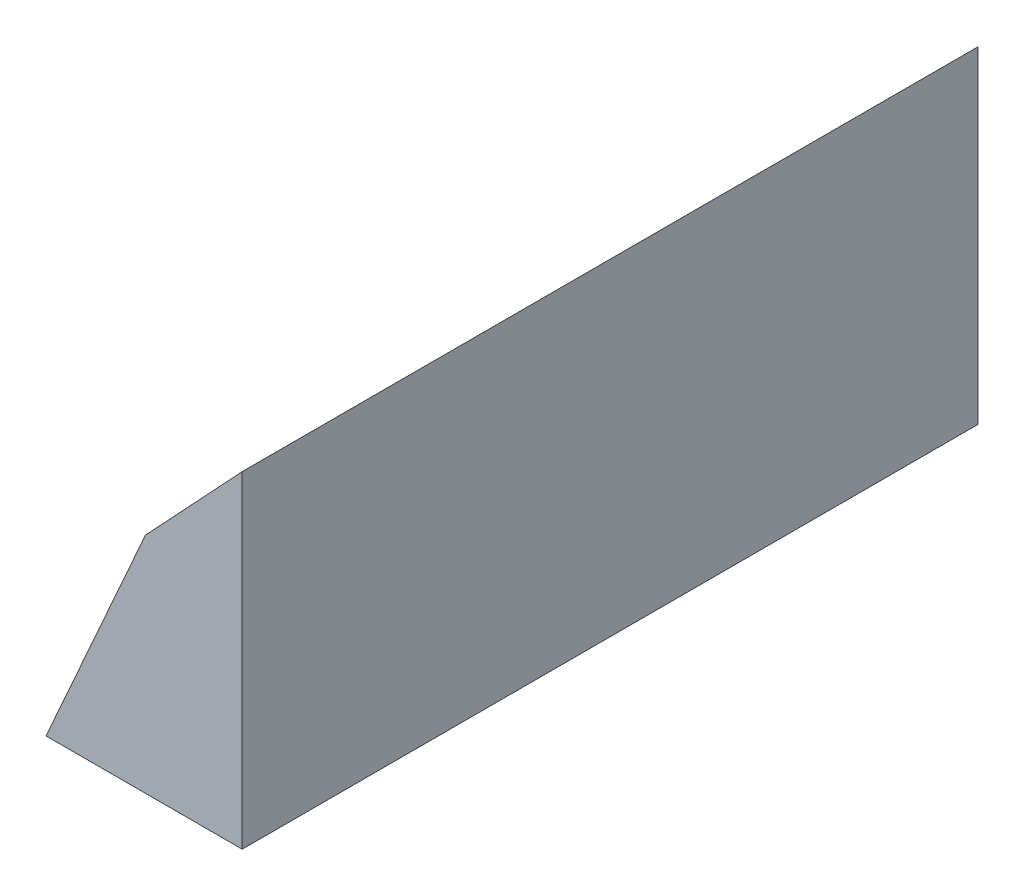
from build123d import *

# Parameters (mm, degrees)
BOSS_EXTRUDE1_DEPTH = 225
SKETCH2_R           = 4.5
CUT_EXTRUDE5_DEPTH  = 101
SKETCH6_R           = 8
CUT_EXTRUDE6_DEPTH  = 98


with BuildPart() as part:
    # Sketch1 → Boss-Extrude1 (new body)
    with BuildSketch(Plane.XY):
        Polygon((-60, -52.594339623), (0, -52.594339623), (0, 47.405660377), (-29.586723225, 15.796476851), align=None)
    extrude(amount=BOSS_EXTRUDE1_DEPTH)

    # Sketch2 → Cut-Extrude5 (cut, through all)
    with BuildSketch(Plane.XZ.offset(52.594339623)):
        with Locations((-30, 202.5)):
            Circle(SKETCH2_R)
        with Locations((-30, 22.5)):
            Circle(SKETCH2_R)
    extrude(amount=-CUT_EXTRUDE5_DEPTH, mode=Mode.SUBTRACT)

    # Sketch6 → Cut-Extrude6 (cut, through all)
    with BuildSketch(Plane(origin=(0, -49.594339623, 0), x_dir=(-1, 0, 0), z_dir=(0, -1, 0))):
        with Locations((30, -22.5)):
            Circle(SKETCH6_R)
        with Locations((30, -202.5)):
            Circle(SKETCH6_R)
    extrude(amount=-CUT_EXTRUDE6_DEPTH, mode=Mode.SUBTRACT)


solid = part.part
